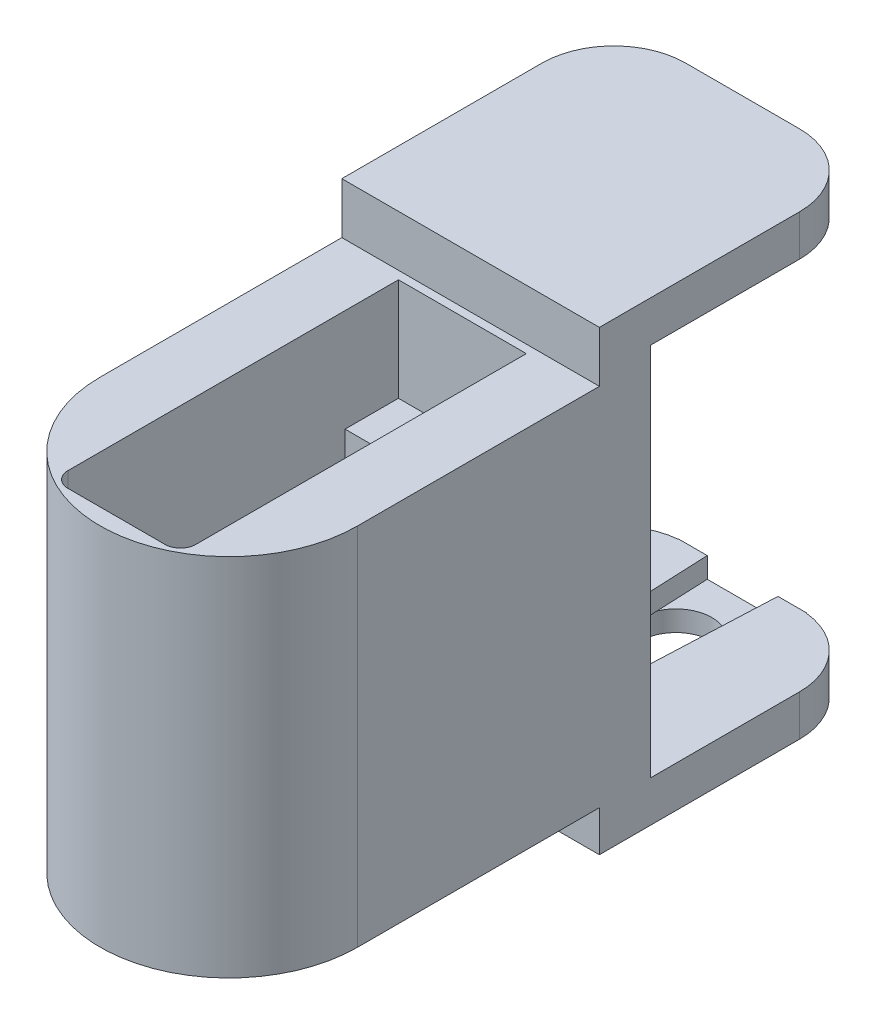
from build123d import *

# Parameters (mm, degrees)
SKETCH4_W                = 12.46
SKETCH4_H                = 17.25
BOSS_EXTRUDE3_DEPTH      = 6
SKETCH8_R                = 12.546781182
SKETCH8_R_2              = 11.15
BOSS_EXTRUDE6_DEPTH      = 8.3
BOSS_EXTRUDE6_DEPTH_BACK = 17.25
BOSS_EXTRUDE4_DEPTH      = 17.25
SKETCH6_R                = 0.75
CUT_EXTRUDE1_DEPTH       = 5
CHAMFER1_SIZE            = 0.5
CHAMFER1_SIZE2           = 0.866025404
SKETCH10_W               = 12.46
SKETCH10_H               = 23.7
CUT_EXTRUDE3_DEPTH       = 17.25
BOSS_EXTRUDE7_DEPTH      = 8.3
BOSS_EXTRUDE9_DEPTH      = 10
SKETCH20_R               = 11.15
SKETCH20_R_2             = 7.15
BOSS_EXTRUDE11_DEPTH     = 8.3
SKETCH21_R               = 10.15
SKETCH21_R_2             = 7.15
CUT_EXTRUDE7_DEPTH       = 1.3
SKETCH11_W               = 10
SKETCH11_H               = 2
CUT_EXTRUDE4_DEPTH       = 23.7
CUT_EXTRUDE8_REACH       = 37.55
SKETCH24_W               = 12.46
SKETCH24_H               = 6
BOSS_EXTRUDE10_DEPTH     = 25.093562
SKETCH18_W               = 21.5
SKETCH18_H               = 12.438292938
CUT_EXTRUDE5_DEPTH       = 2
SKETCH19_R               = 3.5
CUT_EXTRUDE6_DEPTH       = 43.5
CUT_EXTRUDE6_DEPTH_BACK  = 3
FILLET1_R                = 7
SKETCH22_R               = 6.5
BOSS_EXTRUDE12_DEPTH     = 5
SKETCH23_R               = 6.075
BOSS_EXTRUDE13_DEPTH     = 5
FILLET2_R                = 1
BOSS_EXTRUDE15_DEPTH     = 2
CUT_EXTRUDE9_REACH       = 46.5
SKETCH26_R               = 0.75


with BuildPart() as part:
    # Sketch4 → Boss-Extrude3 (new body)
    with BuildSketch(Plane.XY):
        with Locations((0, -1.35)):
            Rectangle(SKETCH4_W, SKETCH4_H)
    extrude(amount=BOSS_EXTRUDE3_DEPTH)



with BuildPart() as body_2:
    # Sketch8 → Boss-Extrude6 (new body, two sides)
    with BuildSketch(Plane(origin=(0, -9.975, 0), x_dir=(-1, 0, 0), z_dir=(0, -1, 0))) as boss_extrude6_sk:
        with Locations((0, -23.55)):
            Circle(SKETCH8_R)
        with Locations((0, -23.55)):
            Circle(SKETCH8_R_2, mode=Mode.SUBTRACT)
    extrude(amount=BOSS_EXTRUDE6_DEPTH)
    extrude(boss_extrude6_sk.sketch, amount=-BOSS_EXTRUDE6_DEPTH_BACK)


with BuildPart() as part_1:
    add(part.part)

    add(body_2.part)  # Boss-Extrude4 merges body 2
    # Sketch5 → Boss-Extrude4 (add)
    with BuildSketch(Plane(origin=(0, 7.275, 0), x_dir=(1, 0, 0), z_dir=(0, 1, 0))):
        with BuildLine():
            Line((12.546781182, -23.55), (12.546781182, 0))
            Line((12.546781182, 0), (6.23, 0))
            Line((6.23, 0), (6.23, -29.7))
            Line((6.23, -29.7), (-6.23, -29.7))
            Line((-6.23, -29.7), (-6.23, 0))
            Line((-6.23, 0), (-12.546781182, 0))
            Line((-12.546781182, 0), (-12.546781182, -23.55))
            ThreePointArc((-12.546781182, -23.55), (0, -36.096781182), (12.546781182, -23.55))
        make_face()
    extrude(amount=-BOSS_EXTRUDE4_DEPTH)

    # Sketch6 → Cut-Extrude1 (cut)
    with BuildSketch(Plane(origin=(0, 7.275, 0), x_dir=(1, 0, 0), z_dir=(0, 1, 0))):
        with Locations((0, -3.6)):
            Circle(SKETCH6_R)
        with Locations((0, -32.1)):
            Circle(SKETCH6_R)
    extrude(amount=-CUT_EXTRUDE1_DEPTH, mode=Mode.SUBTRACT)

    # Chamfer1
    chamfer1_edges = [part_1.edges().sort_by_distance(p)[0] for p in [
        (-0.75, 7.275, 3.6),
        (-0.75, 7.275, 32.1),
    ]]
    chamfer1_side = [part_1.faces().sort_by_distance(p)[0] for p in [
        (0, 7.275, 35.657160381),
    ]]
    chamfer(chamfer1_edges, length=CHAMFER1_SIZE, length2=CHAMFER1_SIZE2, reference=chamfer1_side[0])

    # Sketch10 → Cut-Extrude3 (cut)
    with BuildSketch(Plane(origin=(0, 7.275, 0), x_dir=(1, 0, 0), z_dir=(0, 1, 0))):
        with Locations((0, -17.85)):
            Rectangle(SKETCH10_W, SKETCH10_H)
    extrude(amount=-CUT_EXTRUDE3_DEPTH, mode=Mode.SUBTRACT)

    # Sketch13 → Boss-Extrude7 (add)
    with BuildSketch(Plane.XZ.offset(18.275)):
        with BuildLine():
            Line((-12.546781182, 23.55), (-12.546781182, 0))
            Line((-12.546781182, 0), (12.546781182, 0))
            Line((12.546781182, 0), (12.546781182, 23.55))
            ThreePointArc((12.546781182, 23.55), (0, 11.003218818), (-12.546781182, 23.55))
        make_face()
    extrude(amount=-BOSS_EXTRUDE7_DEPTH)

    # Sketch15 → Boss-Extrude9 (add)
    with BuildSketch(Plane(origin=(0, 7.275, 0), x_dir=(1, 0, 0), z_dir=(0, 1, 0))):
        with BuildLine():
            Line((-12.546781182, 0), (12.546781182, 0))
            Line((12.546781182, 0), (12.546781182, -23.55))
            ThreePointArc((12.546781182, -23.55), (0, -36.096781182), (-12.546781182, -23.55))
            Line((-12.546781182, -23.55), (-12.546781182, 0))
        make_face()
        with BuildLine():
            Line((-6.23, -0.8), (6.23, -0.8))
            Line((6.23, -0.8), (6.23, -33))
            ThreePointArc((6.23, -33), (5.790660172, -34.060660172), (4.73, -34.5))
            Line((4.73, -34.5), (-4.73, -34.5))
            ThreePointArc((-4.73, -34.5), (-5.790660172, -34.060660172), (-6.23, -33))
            Line((-6.23, -33), (-6.23, -0.8))
        make_face(mode=Mode.SUBTRACT)
    extrude(amount=BOSS_EXTRUDE9_DEPTH)

    # Sketch20 → Boss-Extrude11 (add)
    with BuildSketch(Plane.XZ.offset(18.275)):
        with Locations((0, 23.55)):
            Circle(SKETCH20_R)
        with Locations((0, 23.55)):
            Circle(SKETCH20_R_2, mode=Mode.SUBTRACT)
    extrude(amount=-BOSS_EXTRUDE11_DEPTH)

    # Sketch21 → Cut-Extrude7 (cut)
    with BuildSketch(Plane.XZ.offset(18.275)):
        with Locations((0, 23.55)):
            Circle(SKETCH21_R)
        with Locations((0, 23.55)):
            Circle(SKETCH21_R_2, mode=Mode.SUBTRACT)
    extrude(amount=-CUT_EXTRUDE7_DEPTH, mode=Mode.SUBTRACT)

    # Sketch11 → Cut-Extrude4 (cut)
    with BuildSketch(Plane.XY.offset(29.7)):
        with Locations((0, -10.975)):
            Rectangle(SKETCH11_W, SKETCH11_H)
    extrude(amount=-CUT_EXTRUDE4_DEPTH, mode=Mode.SUBTRACT)

    # Sketch24 → Cut-Extrude8 (cut, up to next)
    with BuildSketch(Plane.XZ.offset(18.275), mode=Mode.PRIVATE) as cut_extrude8_sk1:
        with Locations((0, 9)):
            Rectangle(SKETCH24_W, SKETCH24_H)
    cut_extrude8_tool1 = extrude(cut_extrude8_sk1.sketch, amount=-CUT_EXTRUDE8_REACH, mode=Mode.PRIVATE) & part_1.part
    add(cut_extrude8_tool1.solids().sort_by_distance((0, -18.275, 9))[0], mode=Mode.SUBTRACT)

    # Sketch17 → Boss-Extrude10 (add)
    with BuildSketch(Plane(origin=(-12.546781182, 4.728218818, 0), x_dir=(0, -1, 0), z_dir=(1, 0, 0))):
        Polygon((26.978218818, 26.5), (26.978218818, 0), (-17.521781182, 0), (-17.521781182, 26.5), (-13.521781182, 26.5), (-13.521781182, 5), (22.978218818, 5), (22.978218818, 26.5), align=None)
    extrude(amount=BOSS_EXTRUDE10_DEPTH)

    # Sketch18 → Cut-Extrude5 (cut)
    with BuildSketch(Plane.ZX.offset(-18.25)):
        with Locations((-15.75, 0)):
            Rectangle(SKETCH18_W, SKETCH18_H)
    extrude(amount=-CUT_EXTRUDE5_DEPTH, mode=Mode.SUBTRACT)

    # Sketch19 → Cut-Extrude6 (cut, two sides)
    with BuildSketch(Plane.ZX.offset(-20.25)) as cut_extrude6_sk:
        with Locations((-20, 0)):
            Circle(SKETCH19_R)
    extrude(amount=CUT_EXTRUDE6_DEPTH, mode=Mode.SUBTRACT)
    extrude(cut_extrude6_sk.sketch, amount=-CUT_EXTRUDE6_DEPTH_BACK, mode=Mode.SUBTRACT)

    # Fillet1
    fillet1_edges = [part_1.edges().sort_by_distance(p)[0] for p in [
        (12.546780818, -20.25, -26.5),
        (-12.546781182, -20.25, -26.5),
        (12.546780818, 20.25, -26.5),
        (-12.546781182, 20.25, -26.5),
    ]]
    fillet(fillet1_edges, radius=FILLET1_R)

    # Sketch22 → Boss-Extrude12 (add)
    with BuildSketch(Plane(origin=(0, 22.25, 0), x_dir=(1, 0, 0), z_dir=(0, 1, 0))):
        with Locations((0, 20)):
            Circle(SKETCH22_R)
    extrude(amount=-BOSS_EXTRUDE12_DEPTH)

    # Sketch23 → Boss-Extrude13 (add)
    with BuildSketch(Plane.XZ.offset(-17.25)):
        with Locations((0, -20)):
            Circle(SKETCH23_R)
    extrude(amount=BOSS_EXTRUDE13_DEPTH)

    # Fillet2
    fillet2_edges = [part_1.edges().sort_by_distance(p)[0] for p in [
        (-6.075, 12.25, -20),
    ]]
    fillet(fillet2_edges, radius=FILLET2_R)

    # Sketch25 → Boss-Extrude15 (add)
    with BuildSketch(Plane(origin=(0, -20.25, 0), x_dir=(1, 0, 0), z_dir=(0, 1, 0))):
        Polygon((-6.219146469, 5), (-2.5, 5), (-3.1585, 20), (-3.44385, 26.5), (-6.219146469, 26.5), align=None)
        Polygon((6.219146469, 5), (2.5, 5), (3.1585, 20), (3.44385, 26.5), (6.219146469, 26.5), align=None)
    extrude(amount=BOSS_EXTRUDE15_DEPTH)

    # Sketch26 → Cut-Extrude9 (cut, up to next)
    with BuildSketch(Plane(origin=(0, -22.25, 0), x_dir=(-1, 0, 0), z_dir=(0, -1, 0)), mode=Mode.PRIVATE) as cut_extrude9_sk1:
        with Locations((0, 10)):
            Circle(SKETCH26_R)
    cut_extrude9_tool1 = extrude(cut_extrude9_sk1.sketch, amount=-CUT_EXTRUDE9_REACH, mode=Mode.PRIVATE) & part_1.part
    add(cut_extrude9_tool1.solids().sort_by_distance((0, -22.25, -10))[0], mode=Mode.SUBTRACT)


solid = part_1.part
